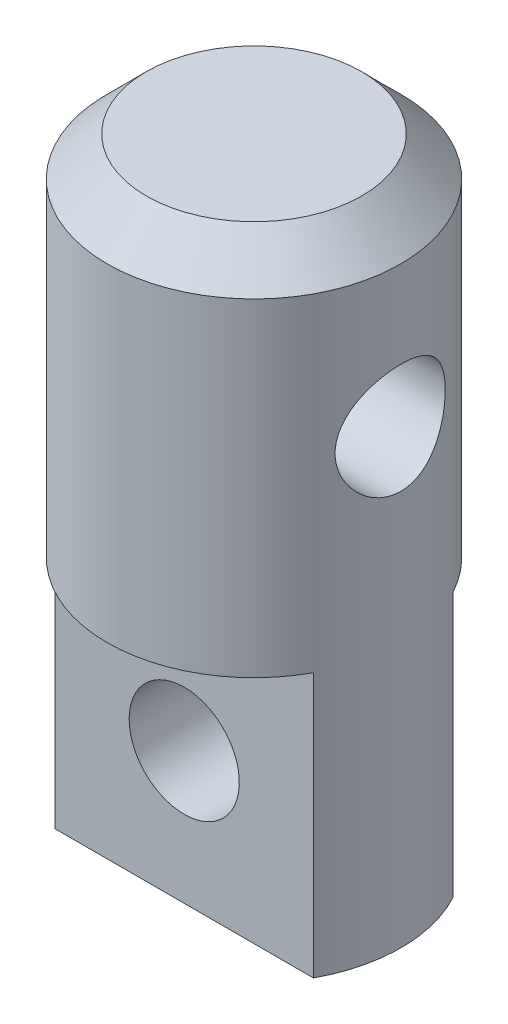
from build123d import *

# Parameters (mm, degrees)
SKETCH1_R               = 6
BOSS_EXTRUDE1_DEPTH     = 25.8
CHAMFER1_SIZE           = 1.6
SKETCH2_W               = 3.15
SKETCH2_H               = 10.8
CUT_EXTRUDE1_DEPTH      = 7
CUT_EXTRUDE1_DEPTH_BACK = 7
SKETCH3_R               = 2.25
CUT_EXTRUDE2_DEPTH      = 4.15
CUT_EXTRUDE2_DEPTH_BACK = 9.85
SKETCH4_R               = 2.25
CUT_EXTRUDE3_DEPTH      = 7
CUT_EXTRUDE3_DEPTH_BACK = 7


with BuildPart() as part:
    # Sketch1 → Boss-Extrude1 (new body)
    with BuildSketch(Plane(origin=(0, 0, 0), x_dir=(1, 0, 0), z_dir=(0, 1, 0))):
        Circle(SKETCH1_R)
    extrude(amount=-BOSS_EXTRUDE1_DEPTH)

    # Chamfer1
    chamfer1_edges = [part.edges().sort_by_distance(p)[0] for p in [
        (-6, 0, 0),
    ]]
    chamfer(chamfer1_edges, length=CHAMFER1_SIZE)

    # Sketch2 → Cut-Extrude1 (cut, two sides)
    with BuildSketch(Plane(origin=(0, 0, 0), x_dir=(0, 0, -1), z_dir=(1, 0, 0))) as cut_extrude1_sk:
        with Locations((4.425, -20.4)):
            Rectangle(SKETCH2_W, SKETCH2_H)
        with Locations((-4.425, -20.4)):
            Rectangle(SKETCH2_W, SKETCH2_H)
    extrude(amount=CUT_EXTRUDE1_DEPTH, mode=Mode.SUBTRACT)
    extrude(cut_extrude1_sk.sketch, amount=-CUT_EXTRUDE1_DEPTH_BACK, mode=Mode.SUBTRACT)

    # Sketch3 → Cut-Extrude2 (cut, two sides)
    with BuildSketch(Plane.XY.offset(2.85)) as cut_extrude2_sk:
        with Locations((0, -20.4)):
            Circle(SKETCH3_R)
    extrude(amount=CUT_EXTRUDE2_DEPTH, mode=Mode.SUBTRACT)
    extrude(cut_extrude2_sk.sketch, amount=-CUT_EXTRUDE2_DEPTH_BACK, mode=Mode.SUBTRACT)

    # Sketch4 → Cut-Extrude3 (cut, two sides)
    with BuildSketch(Plane(origin=(0, 0, 0), x_dir=(0, 0, -1), z_dir=(1, 0, 0))) as cut_extrude3_sk:
        with Locations((0, -7.4)):
            Circle(SKETCH4_R)
    extrude(amount=CUT_EXTRUDE3_DEPTH, mode=Mode.SUBTRACT)
    extrude(cut_extrude3_sk.sketch, amount=-CUT_EXTRUDE3_DEPTH_BACK, mode=Mode.SUBTRACT)


solid = part.part
